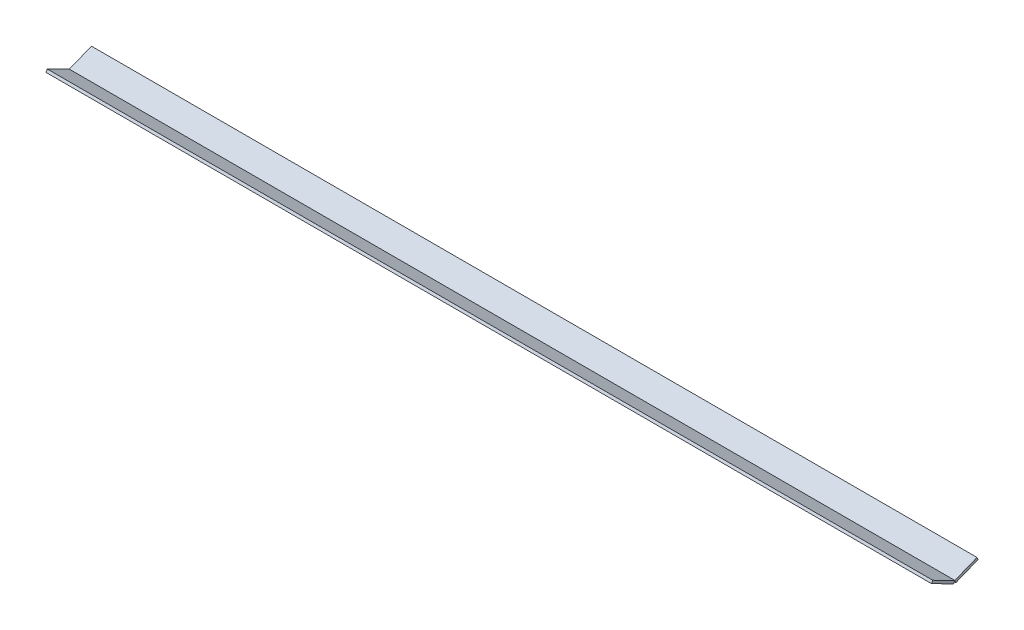
from build123d import *

# Parameters (mm, degrees)
BOSS_EXTRUDE1_DEPTH   = 1000
BOSS_EXTRUDE1_2_DEPTH = 1000


with BuildPart() as part:
    # Sketch2 → Boss-Extrude1 (new body)
    with BuildSketch(Plane(origin=(0, 0, 0), x_dir=(0, 0, -1), z_dir=(1, 0, 0))):
        Polygon((-1.356665076, -2.675716702), (-26.356665076, 10), (-25, 12.675716702), (0, 0), align=None)
    extrude(amount=BOSS_EXTRUDE1_DEPTH)


with BuildPart() as body_2:
    # Sketch2 → Boss-Extrude1 2 (new body)
    with BuildSketch(Plane(origin=(0, 0, 0), x_dir=(0, 0, -1), z_dir=(1, 0, 0))):
        Polygon((25, 10), (26.114172029, 7.214569927), (1.114172029, -2.785430073), (0, 0), align=None)
    extrude(amount=BOSS_EXTRUDE1_2_DEPTH)


solid = Compound([part.part, body_2.part])
